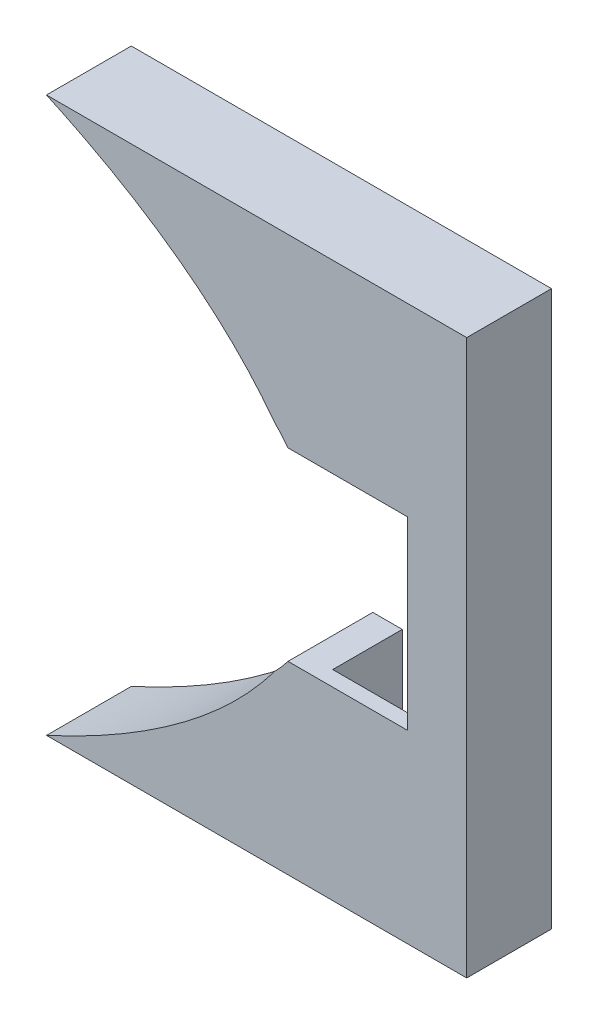
from build123d import *

# Parameters (mm, degrees)
BOSS_EXTRUDE1_DEPTH = 3.3
SKETCH2_W           = 2
SKETCH2_H           = 10.9
BOSS_EXTRUDE2_DEPTH = 0.9
BOSS_EXTRUDE3_DEPTH = 1.7


with BuildPart() as part:
    # Sketch1 → Boss-Extrude1 (new body)
    with BuildSketch(Plane.XY):
        with BuildLine():
            add(Edge.make_bspline(
                [(53.263961031, 6.363961031), (50.163311673, 10.524172065), (45.36862919, 13.803956999), (39.822404925, 16.35)],
                knots=[0, 0, 0, 0, 0.272957657, 0.272957657, 0.272957657, 0.272957657], degree=3))
            ThreePointArc((53.263961031, 6.363961031), (53.678515614, 5.92044982), (54.062227307, 5.45))
            Line((54.062227307, 5.45), (55.8, 5.45))
            Line((55.8, 5.45), (55.8, 14.85))
            Line((55.8, 14.85), (63.1, 14.85))
            Line((63.1, 14.85), (63.1, -14.85))
            Line((63.1, -14.85), (55.8, -14.85))
            Line((55.8, -14.85), (55.8, -5.45))
            Line((55.8, -5.45), (54.062227307, -5.45))
            ThreePointArc((54.062227307, -5.45), (53.678515614, -5.92044982), (53.263961031, -6.363961031))
            add(Edge.make_bspline(
                [(39.822404925, -16.35), (45.36862919, -13.803956999), (50.163311673, -10.524172065), (53.263961031, -6.363961031)],
                knots=[0.727042343, 0.727042343, 0.727042343, 0.727042343, 1, 1, 1, 1], degree=3))
            Line((39.822404925, -16.35), (64.6, -16.35))
            Line((64.6, -16.35), (64.6, 16.35))
            Line((64.6, 16.35), (39.822404925, 16.35))
        make_face()
    extrude(amount=-BOSS_EXTRUDE1_DEPTH)

    # Sketch2 → Boss-Extrude2 (add)
    with BuildSketch(Plane(origin=(0, 0, 0), x_dir=(-1, 0, 0), z_dir=(0, 0, -1))):
        Polygon((-61.1, -5.45), (-63.1, -5.45), (-63.1, -14.85), (-55.8, -14.85), (-55.8, -5.45), align=None)
        Polygon((-55.8, 5.45), (-55.8, 14.85), (-63.1, 14.85), (-63.1, 5.45), (-61.1, 5.45), align=None)
        with Locations((-62.1, 0)):
            Rectangle(SKETCH2_W, SKETCH2_H)
    extrude(amount=BOSS_EXTRUDE2_DEPTH)

    # Sketch3 → Boss-Extrude3 (add)
    with BuildSketch(Plane.XY.offset(-3.3)):
        with BuildLine():
            Line((54.062227307, 5.45), (55.8, 5.45))
            Line((55.8, 5.45), (55.8, 14.85))
            Line((55.8, 14.85), (63.1, 14.85))
            Line((63.1, 14.85), (63.1, -14.85))
            Line((63.1, -14.85), (55.8, -14.85))
            Line((55.8, -14.85), (55.8, -5.45))
            Line((55.8, -5.45), (54.062227307, -5.45))
            ThreePointArc((54.062227307, -5.45), (53.678515614, -5.92044982), (53.263961031, -6.363961031))
            add(Edge.make_bspline(
                [(53.263961031, -6.363961031), (50.163311673, -10.524172065), (45.36862919, -13.803956999), (39.822404925, -16.35)],
                knots=[0.727042343, 0.727042343, 0.727042343, 0.727042343, 1, 1, 1, 1], degree=3))
            Line((39.822404925, -16.35), (64.6, -16.35))
            Line((64.6, -16.35), (64.6, -15.05))
            Line((64.6, -15.05), (64.6, 15.05))
            Line((64.6, 15.05), (64.6, 16.35))
            Line((64.6, 16.35), (39.822404925, 16.35))
            add(Edge.make_bspline(
                [(39.822404925, 16.35), (45.36862919, 13.803956999), (50.163311673, 10.524172065), (53.263961031, 6.363961031)],
                knots=[0, 0, 0, 0, 0.272957657, 0.272957657, 0.272957657, 0.272957657], degree=3))
            ThreePointArc((53.263961031, 6.363961031), (53.678515614, 5.92044982), (54.062227307, 5.45))
        make_face()
    extrude(amount=-BOSS_EXTRUDE3_DEPTH)


solid = part.part
